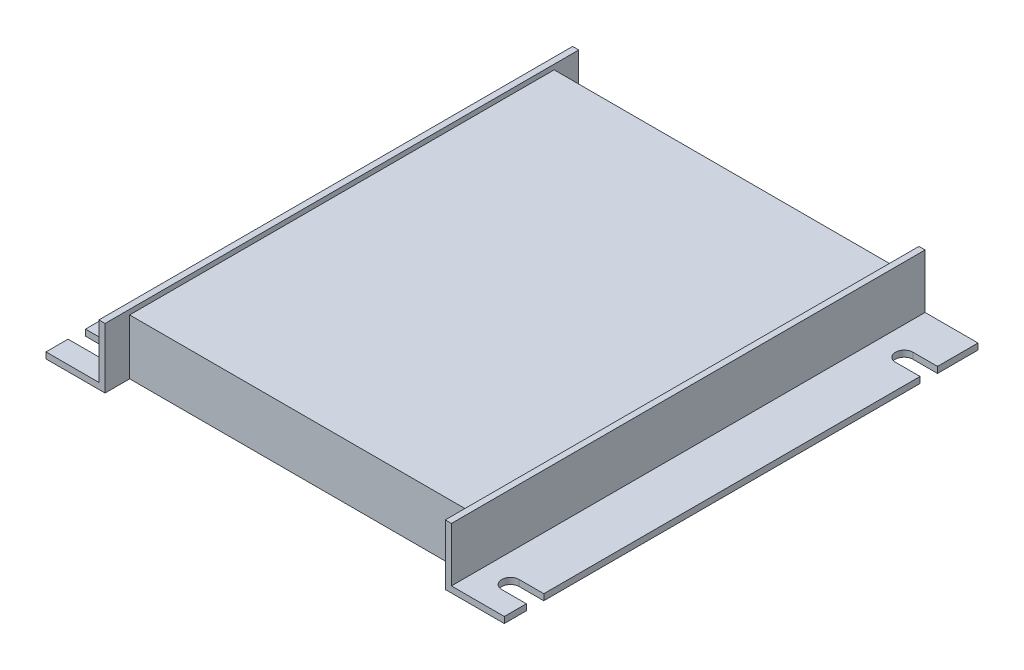
from build123d import *

# Parameters (mm, degrees)
SKETCH2_W           = 118.26875
SKETCH2_H           = 122.2375
BOSS_EXTRUDE1_DEPTH = 1.5875
SKETCH3_W           = 87.78875
SKETCH3_H           = 109.5375
BOSS_EXTRUDE2_DEPTH = 12.7
SKETCH4_W           = 1.5875
SKETCH4_H           = 122.2375
BOSS_EXTRUDE3_DEPTH = 13.97
SKETCH5_W           = 87.78875
SKETCH5_H           = 9.551675444
SKETCH5_H_2         = 9.580916999
CUT_EXTRUDE1_DEPTH  = 2.5875


with BuildPart() as part:
    # Sketch2 → Boss-Extrude1 (new body)
    with BuildSketch(Plane(origin=(0, 0, 0), x_dir=(1, 0, 0), z_dir=(0, 1, 0))):
        with Locations((59.134375, 61.11875)):
            Rectangle(SKETCH2_W, SKETCH2_H)
    extrude(amount=BOSS_EXTRUDE1_DEPTH)

    # Sketch3 → Boss-Extrude2 (add)
    with BuildSketch(Plane(origin=(0, 1.5875, 0), x_dir=(1, 0, 0), z_dir=(0, 1, 0))):
        with Locations((59.134375, 61.11875)):
            Rectangle(SKETCH3_W, SKETCH3_H)
    extrude(amount=BOSS_EXTRUDE2_DEPTH)

    # Sketch4 → Boss-Extrude3 (add)
    with BuildSketch(Plane(origin=(0, 1.5875, 0), x_dir=(1, 0, 0), z_dir=(0, 1, 0))):
        with Locations((14.44625, 61.11875)):
            Rectangle(SKETCH4_W, SKETCH4_H)
        with Locations((103.8225, 61.11875)):
            Rectangle(SKETCH4_W, SKETCH4_H)
    extrude(amount=BOSS_EXTRUDE3_DEPTH)

    # Sketch5 → Cut-Extrude1 (cut, through all)
    with BuildSketch(Plane(origin=(0, 1.5875, 0), x_dir=(1, 0, 0), z_dir=(0, 1, 0))):
        with BuildLine():
            Line((-8.73125, 111.7854), (8.73125, 111.7854))
            ThreePointArc((8.73125, 111.7854), (10.97915, 109.5375), (8.73125, 107.2896))
            Line((8.73125, 107.2896), (-8.73125, 107.2896))
            ThreePointArc((-8.73125, 107.2896), (-10.97915, 109.5375), (-8.73125, 111.7854))
        make_face()
        with BuildLine():
            Line((111.91875, 111.7854), (129.38125, 111.7854))
            ThreePointArc((129.38125, 111.7854), (131.62915, 109.5375), (129.38125, 107.2896))
            Line((129.38125, 107.2896), (111.91875, 107.2896))
            ThreePointArc((111.91875, 107.2896), (109.67085, 109.5375), (111.91875, 111.7854))
        make_face()
        with BuildLine():
            Line((111.91875, 10.1854), (129.38125, 10.1854))
            ThreePointArc((129.38125, 10.1854), (131.62915, 7.9375), (129.38125, 5.6896))
            Line((129.38125, 5.6896), (111.91875, 5.6896))
            ThreePointArc((111.91875, 5.6896), (109.67085, 7.9375), (111.91875, 10.1854))
        make_face()
        with BuildLine():
            Line((-8.73125, 10.1854), (8.73125, 10.1854))
            ThreePointArc((8.73125, 10.1854), (10.97915, 7.9375), (8.73125, 5.6896))
            Line((8.73125, 5.6896), (-8.73125, 5.6896))
            ThreePointArc((-8.73125, 5.6896), (-10.97915, 7.9375), (-8.73125, 10.1854))
        make_face()
        with Locations((59.134375, 120.663337722)):
            Rectangle(SKETCH5_W, SKETCH5_H)
        with Locations((59.134375, 1.559541501)):
            Rectangle(SKETCH5_W, SKETCH5_H_2)
    extrude(amount=-CUT_EXTRUDE1_DEPTH, mode=Mode.SUBTRACT)


solid = part.part
